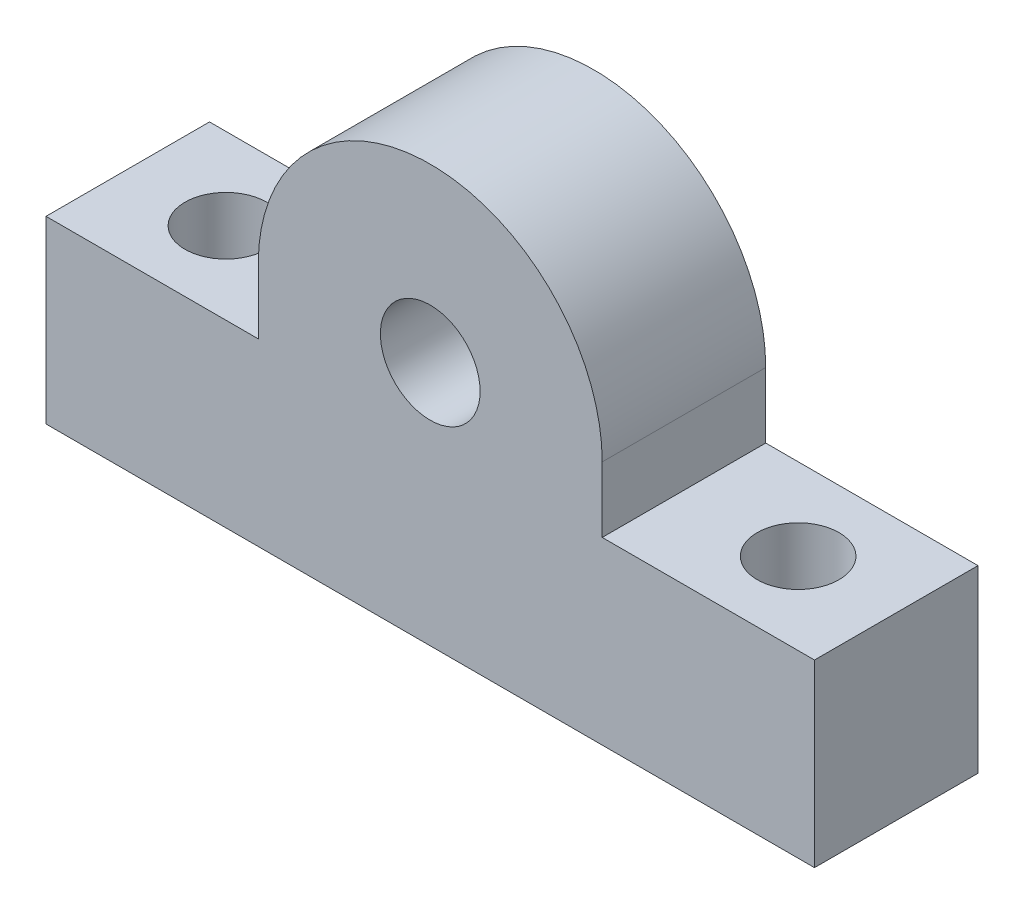
from build123d import *

# Parameters (mm, degrees)
SKETCH1_W           = 47
SKETCH1_H           = 11
BOSS_EXTRUDE1_DEPTH = 10
CUT_EXTRUDE1_REACH  = 29.807
SKETCH3_R           = 2.5
BOSS_EXTRUDE3_DEPTH = 10


with BuildPart() as part:
    # Sketch1 → Boss-Extrude1 (new body)
    with BuildSketch(Plane.XY):
        Rectangle(SKETCH1_W, SKETCH1_H)
    extrude(amount=BOSS_EXTRUDE1_DEPTH)

    # Sketch3 → Cut-Extrude1 (cut, up to next)
    with BuildSketch(Plane.XZ.offset(5.5), mode=Mode.PRIVATE) as cut_extrude1_sk1:
        with BuildLine():
            ThreePointArc((-20, 5), (-17.5, 2.5), (-15, 5))
            Line((-15, 5), (-17.5, 5))
            Line((-17.5, 5), (-20, 5))
        make_face()
    cut_extrude1_tool1 = extrude(cut_extrude1_sk1.sketch, amount=-CUT_EXTRUDE1_REACH, mode=Mode.PRIVATE) & part.part
    # Sketch3 → Cut-Extrude1 (cut, up to next)
    with BuildSketch(Plane.XZ.offset(5.5), mode=Mode.PRIVATE) as cut_extrude1_sk2:
        with BuildLine():
            Line((-17.5, 5), (-15, 5))
            ThreePointArc((-15, 5), (-17.5, 7.5), (-20, 5))
            Line((-20, 5), (-17.5, 5))
        make_face()
    cut_extrude1_tool2 = extrude(cut_extrude1_sk2.sketch, amount=-CUT_EXTRUDE1_REACH, mode=Mode.PRIVATE) & part.part
    # Sketch3 → Cut-Extrude1 (cut, up to next)
    with BuildSketch(Plane.XZ.offset(5.5), mode=Mode.PRIVATE) as cut_extrude1_sk3:
        with BuildLine():
            ThreePointArc((-20, 5), (-17.5, 2.5), (-15, 5))
            Line((-15, 5), (-17.5, 5))
            Line((-17.5, 5), (-20, 5))
        make_face()
    cut_extrude1_tool3 = extrude(cut_extrude1_sk3.sketch, amount=-CUT_EXTRUDE1_REACH, mode=Mode.PRIVATE) & part.part
    # Sketch3 → Cut-Extrude1 (cut, up to next)
    with BuildSketch(Plane.XZ.offset(5.5), mode=Mode.PRIVATE) as cut_extrude1_sk4:
        with BuildLine():
            Line((-17.5, 5), (-15, 5))
            ThreePointArc((-15, 5), (-17.5, 7.5), (-20, 5))
            Line((-20, 5), (-17.5, 5))
        make_face()
    cut_extrude1_tool4 = extrude(cut_extrude1_sk4.sketch, amount=-CUT_EXTRUDE1_REACH, mode=Mode.PRIVATE) & part.part
    # Sketch3 → Cut-Extrude1 (cut, up to next)
    with BuildSketch(Plane.XZ.offset(5.5), mode=Mode.PRIVATE) as cut_extrude1_sk5:
        with Locations(Location((17.5, 5, 0), (0, 0, 270))):
            Circle(SKETCH3_R)
    cut_extrude1_tool5 = extrude(cut_extrude1_sk5.sketch, amount=-CUT_EXTRUDE1_REACH, mode=Mode.PRIVATE) & part.part
    add(cut_extrude1_tool1.solids().sort_by_distance((-17.5, -5.5, 3.938967))[0], mode=Mode.SUBTRACT)
    add(cut_extrude1_tool2.solids().sort_by_distance((-17.5, -5.5, 6.061033))[0], mode=Mode.SUBTRACT)
    add(cut_extrude1_tool3.solids().sort_by_distance((-17.5, -5.5, 3.938967))[0], mode=Mode.SUBTRACT)
    add(cut_extrude1_tool4.solids().sort_by_distance((-17.5, -5.5, 6.061033))[0], mode=Mode.SUBTRACT)
    add(cut_extrude1_tool5.solids().sort_by_distance((17.5, -5.5, 5))[0], mode=Mode.SUBTRACT)

    # Sketch4 → Boss-Extrude3 (add)
    with BuildSketch(Plane.XY.offset(10)):
        with BuildLine():
            Line((-10.517377717, 5.5), (0, 5.5))
            Line((0, 5.5), (10.517377717, 5.5))
            Line((10.517377717, 5.5), (10.517377717, 9.5))
            ThreePointArc((10.517377717, 9.5), (0, 20.017377717), (-10.517377717, 9.5))
            Line((-10.517377717, 9.5), (-10.517377717, 5.5))
        make_face()
        with BuildLine():
            ThreePointArc((3.05, 9.5), (2.156675683, 7.343324317), (0, 6.45))
            ThreePointArc((0, 6.45), (-2.156675683, 11.656675683), (3.05, 9.5))
        make_face(mode=Mode.SUBTRACT)
    extrude(amount=-BOSS_EXTRUDE3_DEPTH)


solid = part.part
